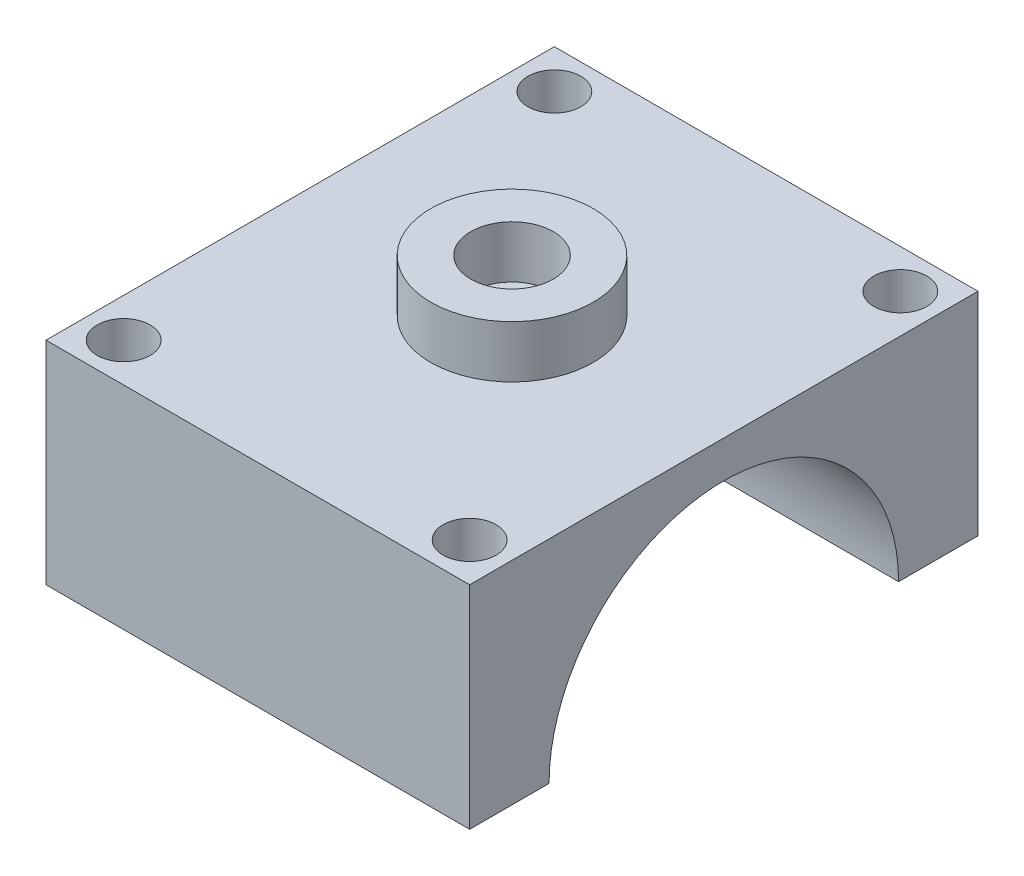
from build123d import *

# Parameters (mm, degrees)
SKETCH1_W           = 30
SKETCH1_H           = 36
BOSS_EXTRUDE1_DEPTH = 30
SKETCH3_R           = 12.375
CUT_EXTRUDE1_DEPTH  = 40
SKETCH5_R           = 1.875
CUT_EXTRUDE2_DEPTH  = 40
CUT_EXTRUDE3_START  = 15
SKETCH7_W           = 36
SKETCH7_H           = 15
CUT_EXTRUDE3_DEPTH  = 31
SKETCH8_R           = 5.75
BOSS_EXTRUDE2_DEPTH = 3.7
SKETCH11_R          = 2.92
CUT_EXTRUDE5_DEPTH  = 3.7
SKETCH12_R          = 1.75
CUT_EXTRUDE6_DEPTH  = 3.7
SKETCH14_R          = 2.55
CUT_EXTRUDE8_DEPTH  = 13.5


with BuildPart() as part:
    # Sketch1 → Boss-Extrude1 (new body)
    with BuildSketch(Plane(origin=(0, 0, 0), x_dir=(1, 0, 0), z_dir=(0, 1, 0))):
        Rectangle(SKETCH1_W, SKETCH1_H)
    extrude(amount=BOSS_EXTRUDE1_DEPTH)

    # Sketch3 → Cut-Extrude1 (cut)
    with BuildSketch(Plane(origin=(15, 0, 0), x_dir=(0, 0, -1), z_dir=(1, 0, 0))):
        with Locations((0, 15)):
            Circle(SKETCH3_R)
    extrude(amount=-CUT_EXTRUDE1_DEPTH, mode=Mode.SUBTRACT)

    # Sketch5 → Cut-Extrude2 (cut)
    with BuildSketch(Plane(origin=(0, 30, 0), x_dir=(1, 0, 0), z_dir=(0, 1, 0))):
        with Locations((-12.25, 15.25)):
            Circle(SKETCH5_R)
        with Locations((-12.25, -15.25)):
            Circle(SKETCH5_R)
        with Locations((12.25, -15.25)):
            Circle(SKETCH5_R)
        with Locations((12.25, 15.25)):
            Circle(SKETCH5_R)
    extrude(amount=-CUT_EXTRUDE2_DEPTH, mode=Mode.SUBTRACT)

    # Sketch7 → Cut-Extrude3 (cut, through all)
    with BuildSketch(Plane(origin=(0, 0, 0), x_dir=(0, 0, -1), z_dir=(1, 0, 0)).offset(CUT_EXTRUDE3_START)):
        with Locations((0, 7.5)):
            Rectangle(SKETCH7_W, SKETCH7_H)
    extrude(amount=-CUT_EXTRUDE3_DEPTH, mode=Mode.SUBTRACT)

    # Sketch8 → Boss-Extrude2 (add)
    with BuildSketch(Plane(origin=(0, 30, 0), x_dir=(1, 0, 0), z_dir=(0, 1, 0))):
        Circle(SKETCH8_R)
    extrude(amount=BOSS_EXTRUDE2_DEPTH)

    # Sketch11 → Cut-Extrude5 (cut)
    with BuildSketch(Plane(origin=(0, 33.7, 0), x_dir=(1, 0, 0), z_dir=(0, 1, 0))):
        Circle(SKETCH11_R)
    extrude(amount=-CUT_EXTRUDE5_DEPTH, mode=Mode.SUBTRACT)

    # Sketch12 → Cut-Extrude6 (cut)
    with BuildSketch(Plane(origin=(0, 30, 0), x_dir=(1, 0, 0), z_dir=(0, 1, 0))):
        Circle(SKETCH12_R)
    extrude(amount=-CUT_EXTRUDE6_DEPTH, mode=Mode.SUBTRACT)

    # Sketch14 → Cut-Extrude8 (cut)
    with BuildSketch(Plane.XZ.offset(-15)):
        Circle(SKETCH14_R)
    extrude(amount=-CUT_EXTRUDE8_DEPTH, mode=Mode.SUBTRACT)


solid = part.part
